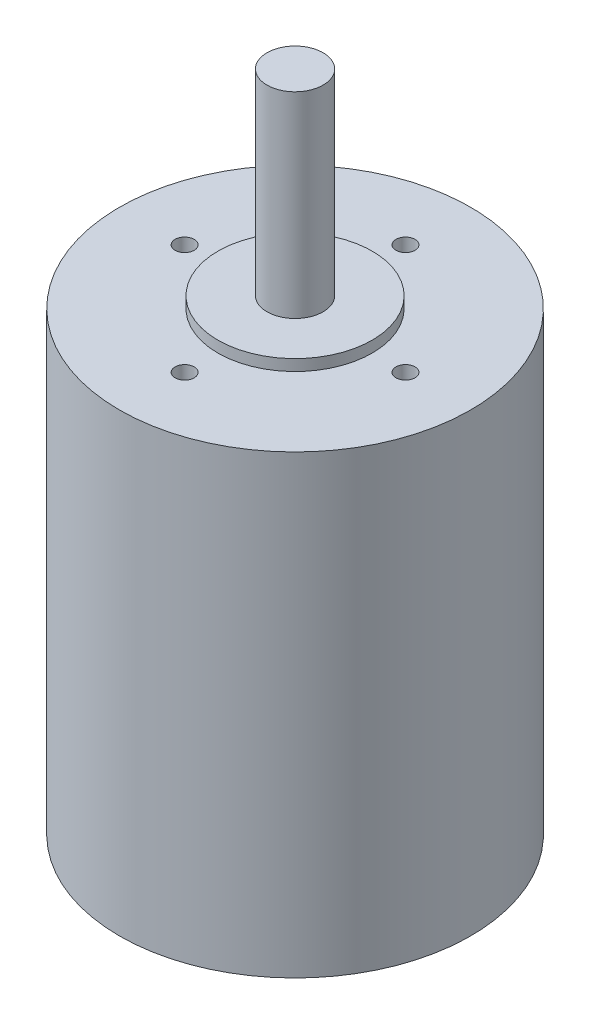
from build123d import *

# Parameters (mm, degrees)
SKETCH1_R           = 39.751
BOSS_EXTRUDE1_DEPTH = 103.124
SKETCH2_R           = 17.4625
BOSS_EXTRUDE2_DEPTH = 2.54
SKETCH3_R           = 6.35
BOSS_EXTRUDE3_DEPTH = 44.45
SKETCH4_R           = 2.159
CUT_EXTRUDE1_DEPTH  = 44.45


with BuildPart() as part:
    # Sketch1 → Boss-Extrude1 (new body)
    with BuildSketch(Plane(origin=(0, 0, 0), x_dir=(1, 0, 0), z_dir=(0, 1, 0))):
        Circle(SKETCH1_R)
    extrude(amount=BOSS_EXTRUDE1_DEPTH)

    # Sketch2 → Boss-Extrude2 (add)
    with BuildSketch(Plane(origin=(0, 103.124, 0), x_dir=(1, 0, 0), z_dir=(0, 1, 0))):
        Circle(SKETCH2_R)
    extrude(amount=BOSS_EXTRUDE2_DEPTH)

    # Sketch3 → Boss-Extrude3 (add)
    with BuildSketch(Plane(origin=(0, 105.664, 0), x_dir=(1, 0, 0), z_dir=(0, 1, 0))):
        Circle(SKETCH3_R)
    extrude(amount=BOSS_EXTRUDE3_DEPTH)

    # Sketch4 → Cut-Extrude1 (cut)
    with BuildSketch(Plane(origin=(0, 103.124, 0), x_dir=(1, 0, 0), z_dir=(0, 1, 0))):
        with Locations((0, 25)):
            Circle(SKETCH4_R)
        with Locations((25, 0)):
            Circle(SKETCH4_R)
        with Locations((0, -25)):
            Circle(SKETCH4_R)
        with Locations((-25, 0)):
            Circle(SKETCH4_R)
    extrude(amount=-CUT_EXTRUDE1_DEPTH, mode=Mode.SUBTRACT)


solid = part.part
